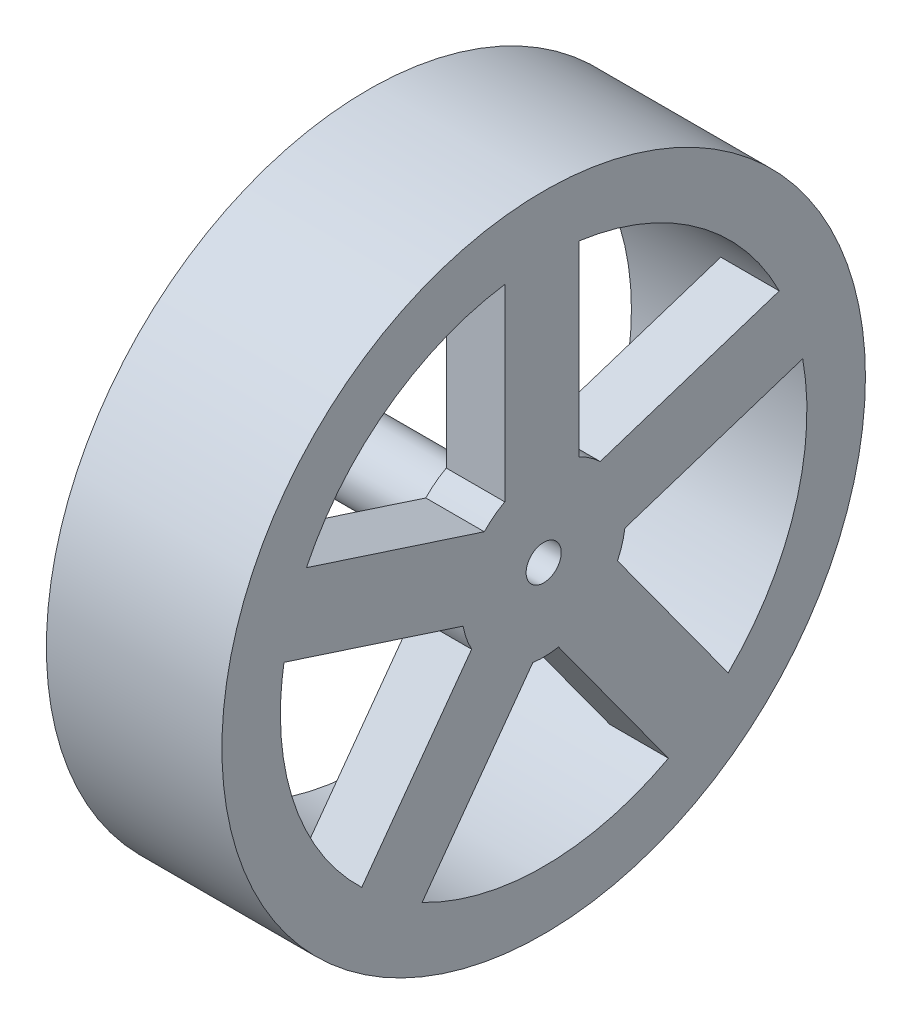
from build123d import *

# Parameters (mm, degrees)
SKETCH1_R           = 27.5
BOSS_EXTRUDE1_DEPTH = 15
SKETCH2_R           = 1.5
CUT_EXTRUDE1_DEPTH  = 16
SKETCH3_R           = 22.5
SKETCH3_R_2         = 3
CUT_EXTRUDE2_DEPTH  = 10
SKETCH4_R           = 3
SKETCH4_R_2         = 1.5
BOSS_EXTRUDE2_DEPTH = 3
CUT_EXTRUDE3_DEPTH  = 6


with BuildPart() as part:
    # Sketch1 → Boss-Extrude1 (new body)
    with BuildSketch(Plane(origin=(0, 0, 0), x_dir=(0, 0, -1), z_dir=(1, 0, 0))):
        Circle(SKETCH1_R)
    extrude(amount=BOSS_EXTRUDE1_DEPTH)

    # Sketch2 → Cut-Extrude1 (cut, through all)
    with BuildSketch(Plane(origin=(15, 0, 0), x_dir=(0, 0, -1), z_dir=(1, 0, 0))):
        Circle(SKETCH2_R)
    extrude(amount=-CUT_EXTRUDE1_DEPTH, mode=Mode.SUBTRACT)

    # Sketch3 → Cut-Extrude2 (cut)
    with BuildSketch(Plane.ZY):
        Circle(SKETCH3_R)
        Circle(SKETCH3_R_2, mode=Mode.SUBTRACT)
    extrude(amount=-CUT_EXTRUDE2_DEPTH, mode=Mode.SUBTRACT)

    # Sketch4 → Boss-Extrude2 (add)
    with BuildSketch(Plane.ZY):
        Circle(SKETCH4_R)
        Circle(SKETCH4_R_2, mode=Mode.SUBTRACT)
    extrude(amount=BOSS_EXTRUDE2_DEPTH)

    # Sketch5 → Cut-Extrude3 (cut, through all)
    with BuildSketch(Plane.ZY.offset(-10)):
        with BuildLine():
            Line((5.074237821, 4.822044228), (20.272779151, 9.76034966))
            ThreePointArc((20.272779151, 9.76034966), (13.350301343, 18.111307353), (3.325036991, 22.252957759))
            Line((3.325036991, 22.252957759), (3.325036991, 6.1598806))
            ThreePointArc((3.325036991, 6.1598806), (4.252576382, 5.560179324), (5.074237821, 4.822044228))
        make_face()
        with BuildLine():
            Line((-3.018010865, 6.315980559), (-3.018010865, 22.296672631))
            ThreePointArc((-3.018010865, 22.296672631), (-13.099406882, 18.293592849), (-20.136327546, 10.03884022))
            Line((-20.136327546, 10.03884022), (-4.830901647, 5.065805886))
            ThreePointArc((-4.830901647, 5.065805886), (-3.973926406, 5.762630382), (-3.018010865, 6.315980559))
        make_face()
        with BuildLine():
            Line((-6.939471114, -0.91855357), (-22.138012444, 4.019751862))
            ThreePointArc((-22.138012444, 4.019751862), (-21.446180029, -6.805245196), (-15.769971823, -16.048613295))
            Line((-15.769971823, -16.048613295), (-6.310698406, -3.029040382))
            ThreePointArc((-6.310698406, -3.029040382), (-6.70859797, -1.998677884), (-6.939471114, -0.91855357))
        make_face()
        with BuildLine():
            Line((10.389948957, -19.957428709), (0.93067554, -6.937855796))
            ThreePointArc((0.93067554, -6.937855796), (-0.172215156, -6.997881246), (-1.270818148, -6.883677886))
            Line((-1.270818148, -6.883677886), (-10.664033269, -19.812329354))
            ThreePointArc((-10.664033269, -19.812329354), (-0.155061304, -22.499465682), (10.389948957, -19.957428709))
        make_face()
        with BuildLine():
            ThreePointArc((22.5, 0), (22.422695556, 1.863524623), (22.19131342, 3.714244025))
            Line((22.19131342, 3.714244025), (6.885887521, -1.258790309))
            ThreePointArc((6.885887521, -1.258790309), (6.60216315, -2.326250576), (6.154062305, -3.335793331))
            Line((6.154062305, -3.335793331), (15.547277427, -16.264444799))
            ThreePointArc((15.547277427, -16.264444799), (20.688931124, -8.844101365), (22.5, 0))
        make_face()
    extrude(amount=-CUT_EXTRUDE3_DEPTH, mode=Mode.SUBTRACT)


solid = part.part
